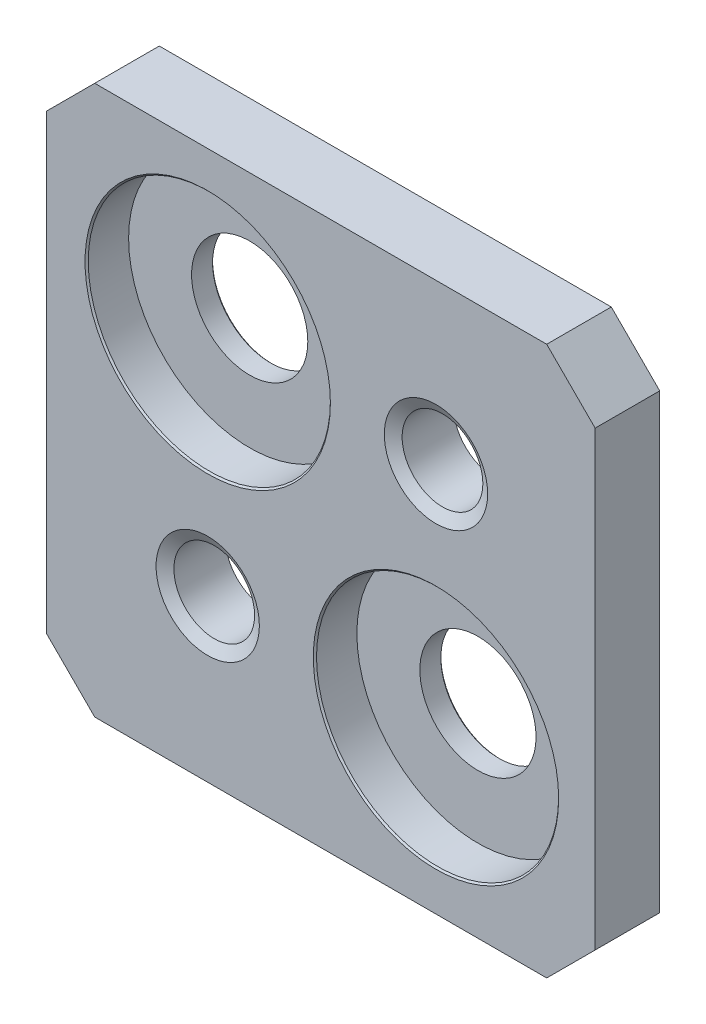
from build123d import *

# Parameters (mm, degrees)
SKETCH_1_R                 = 1
EXTRUDE_1_DEPTH            = 2
M3X0_51_AT_2_COUNT         = 2
M3X0_51_AT_2_PITCH         = 9.998489886
HOLE_WIZARD_M31_AT_2_COUNT = 2
HOLE_WIZARD_M31_AT_2_PITCH = 9.998489886


with BuildPart() as part:
    # Эскиз1 → Бобышка-Вытянуть1 (new body)
    with BuildSketch(Plane.XY):
        Polygon((0, 15.5), (1.5, 17), (15.5, 17), (17, 15.5), (17, 1.5), (15.5, 0), (1.5, 0), (0, 1.5), align=None)
        with Locations((5, 5)):
            Circle(SKETCH_1_R, mode=Mode.SUBTRACT)
        with Locations((12.07, 5)):
            Circle(SKETCH_1_R, mode=Mode.SUBTRACT)
        with Locations((12.07, 12.07)):
            Circle(SKETCH_1_R, mode=Mode.SUBTRACT)
        with Locations((5, 12.07)):
            Circle(SKETCH_1_R, mode=Mode.SUBTRACT)
    extrude(amount=EXTRUDE_1_DEPTH)

    # Эскиз2 → Отверстие обработанное метчиком M3x0.51 (revolve, cut)
    with BuildSketch(Plane(origin=(12.07, 12.07, 2), x_dir=(0, -1, 0), z_dir=(1, 0, 0))):
        Polygon((0, 0), (0, 2), (1.6, 2), (1.25, 1.797927406), (1.25, 0.202072594), (1.6, 0), align=None)
    m3x0_51 = revolve(axis=Axis((12.07, 12.07, 8.35), (0, 0, -1)), mode=Mode.SUBTRACT)

    # Отверстие обработанное метчиком M3x0.51 at 2: Отверстие обработанное метчиком M3x0.51 ×2
    with Locations(*[Vector(-0.707106781, -0.707106781, 0) * (i * M3X0_51_AT_2_PITCH) for i in range(1, M3X0_51_AT_2_COUNT)]):
        add(m3x0_51, mode=Mode.SUBTRACT)

    # Эскиз4 → Цековка для винта с заклепочной головкой M31 (revolve, cut)
    with BuildSketch(Plane(origin=(5, 12.07, 2), x_dir=(0, -1, 0), z_dir=(1, 0, 0))):
        Polygon((0, 0), (0, 2), (1.85, 2), (1.8, 1.95), (1.8, 1.3), (3.75, 1.3), (3.75, 0.05), (3.8, 0), align=None)
    hole_wizard_m31 = revolve(axis=Axis((5, 12.07, 8.35), (0, 0, -1)), mode=Mode.SUBTRACT)

    # Цековка для винта с заклепочной головкой M31 at 2: Цековка для винта с заклепочной головкой M31 ×2
    with Locations(*[Vector(0.707106781, -0.707106781, 0) * (i * HOLE_WIZARD_M31_AT_2_PITCH) for i in range(1, HOLE_WIZARD_M31_AT_2_COUNT)]):
        add(hole_wizard_m31, mode=Mode.SUBTRACT)


solid = part.part
